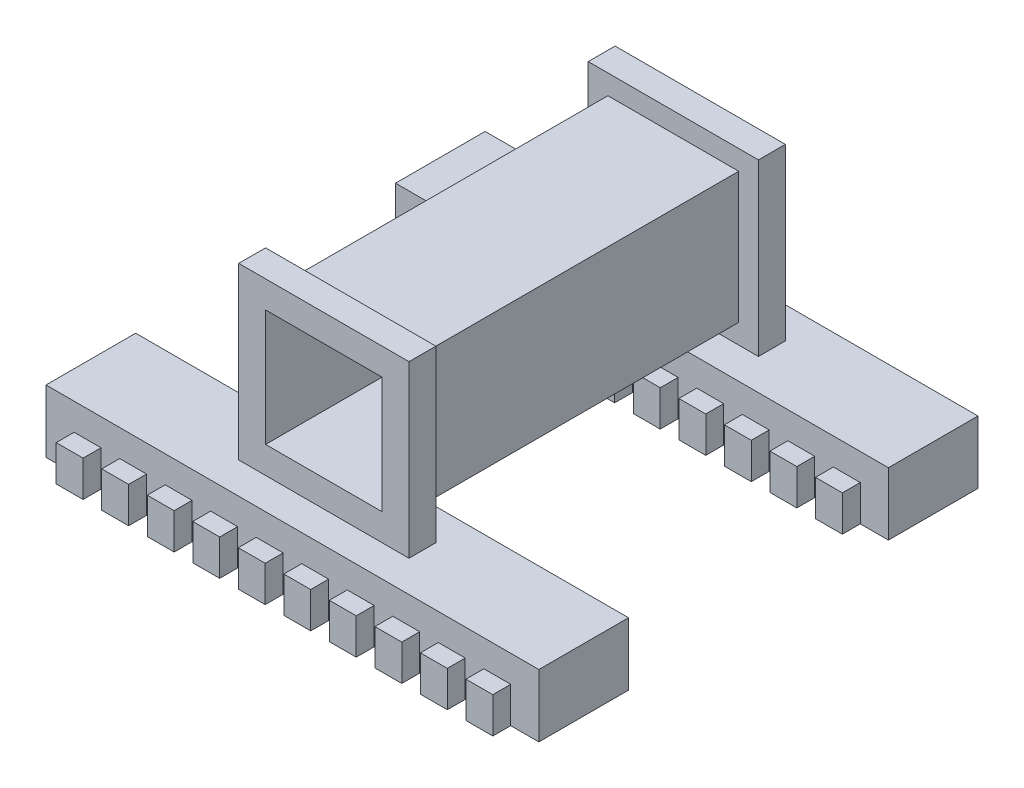
from build123d import *

# Parameters (mm, degrees)
EXTRUDE_1_DEPTH      = 21
SKETCH_1_3_W         = 13
SKETCH_1_3_H         = 13
CUT_EXTRUDE_1_DEPTH  = 21
SKETCH_1_12_W        = 19
SKETCH_1_12_H        = 19
SKETCH_1_12_W_2      = 14.6
SKETCH_1_12_H_2      = 14.6
SKETCH_1_12_W_3      = 13
SKETCH_1_12_H_3      = 13
CUT_EXTRUDE_6_DEPTH  = 18
CUT_EXTRUDE_7_DEPTH  = 14.5
SKETCH_4_W           = 3.504900739
SKETCH_4_H           = 7
SKETCH_4_W_2         = 3.5
EXTRUDE_2_DEPTH      = 27.5
SKETCH_10_W          = 1
SKETCH_10_H          = 7
EXTRUDE_4_DEPTH      = 55
SKETCH_14_W          = 1
SKETCH_14_H          = 7
EXTRUDE_6_DEPTH      = 55
SKETCH_26_W          = 1
SKETCH_26_H          = 7
EXTRUDE_7_DEPTH      = 55
CUT_EXTRUDE_27_DEPTH = 2
CUT_EXTRUDE_28_DEPTH = 2
CUT_EXTRUDE_29_DEPTH = 2
CUT_EXTRUDE_30_DEPTH = 2
SKETCH_31_W          = 49.72
SKETCH_31_H          = 3
CUT_EXTRUDE_31_DEPTH = 4


with BuildPart() as part:
    # 草图1 → 凸台-拉伸1 (new, symmetric)
    with BuildSketch(Plane.XY):
        Polygon((9.5, 9.5), (-9.5, 9.5), (-9.5, -9.5), (-27.5, -9.5), (-27.5, -16.5), (27.5, -16.5), (27.5, -9.5), (9.5, -9.5), align=None)
    extrude(amount=EXTRUDE_1_DEPTH, both=True)

    # 草图1<3> → 切除-拉伸1 (cut, symmetric)
    with BuildSketch(Plane.XY):
        Rectangle(SKETCH_1_3_W, SKETCH_1_3_H)
    extrude(amount=CUT_EXTRUDE_1_DEPTH, both=True, mode=Mode.SUBTRACT)

    # 草图1<12> → 切除-拉伸6 (cut, symmetric)
    # profile 1 of 2: a face of its own
    with BuildSketch(Plane.XY):
        Rectangle(SKETCH_1_12_W, SKETCH_1_12_H)
        Rectangle(SKETCH_1_12_W_2, SKETCH_1_12_H_2, mode=Mode.SUBTRACT)
    # profile 2 of 2: a face of its own
    with BuildSketch(Plane.XY):
        Rectangle(SKETCH_1_12_W_3, SKETCH_1_12_H_3)
    extrude(amount=CUT_EXTRUDE_6_DEPTH, both=True, mode=Mode.SUBTRACT)

    # 草图1<13> → 切除-拉伸7 (cut, symmetric)
    with BuildSketch(Plane.XY):
        Polygon((9.5, -9.5), (-9.5, -9.5), (-27.5, -9.5), (-27.5, -16.5), (27.5, -16.5), (27.5, -9.5), align=None)
    extrude(amount=CUT_EXTRUDE_7_DEPTH, both=True, mode=Mode.SUBTRACT)

    # 草图4 → 凸台-拉伸2 (add, symmetric)
    with BuildSketch(Plane(origin=(0, 0, 0), x_dir=(0, 0, -1), z_dir=(1, 0, 0))):
        with Locations((-22.752450369, -13)):
            Rectangle(SKETCH_4_W, SKETCH_4_H)
        with Locations((22.75, -13)):
            Rectangle(SKETCH_4_W_2, SKETCH_4_H)
    extrude(amount=EXTRUDE_2_DEPTH, both=True)

    # 草图10 → 凸台-拉伸4 (add)
    with BuildSketch(Plane(origin=(27.5, 0, 0), x_dir=(0, 0, -1), z_dir=(1, 0, 0))):
        with Locations((-25.004900739, -13)):
            Rectangle(SKETCH_10_W, SKETCH_10_H)
        with Locations((-14, -13)):
            Rectangle(SKETCH_10_W, SKETCH_10_H)
    extrude(amount=-EXTRUDE_4_DEPTH)

    # 草图14 → 凸台-拉伸6 (add)
    with BuildSketch(Plane(origin=(27.5, 0, 0), x_dir=(0, 0, -1), z_dir=(1, 0, 0))):
        with Locations((14, -13)):
            Rectangle(SKETCH_14_W, SKETCH_14_H)
        with Locations((25, -13)):
            Rectangle(SKETCH_14_W, SKETCH_14_H)
    extrude(amount=-EXTRUDE_6_DEPTH)

    # 草图26 → 凸台-拉伸7 (add)
    with BuildSketch(Plane(origin=(27.5, 0, 0), x_dir=(0, 0, -1), z_dir=(1, 0, 0))):
        with Locations((26, -13)):
            Rectangle(SKETCH_26_W, SKETCH_26_H)
        with Locations((13, -13)):
            Rectangle(SKETCH_26_W, SKETCH_26_H)
        with Locations((-13, -13)):
            Rectangle(SKETCH_26_W, SKETCH_26_H)
        with Locations((-26.004900739, -13)):
            Rectangle(SKETCH_26_W, SKETCH_26_H)
    extrude(amount=-EXTRUDE_7_DEPTH)

    # 草图27 → 切除-拉伸27 (cut)
    with BuildSketch(Plane(origin=(0, 0, -26.5), x_dir=(-1, 0, 0), z_dir=(0, 0, -1))):
        Polygon((-24.36, -12.5), (-22.86, -12.5), (-21.36, -12.5), (-21.36, -16.5), (-19.28, -16.5), (-19.28, -12.5), (-17.78, -12.5), (-16.28, -12.5), (-16.28, -16.5), (-14.2, -16.5), (-14.2, -12.5), (-12.7, -12.5), (-11.2, -12.5), (-11.2, -16.5), (-9.12, -16.5), (-9.12, -12.5), (-7.62, -12.5), (-6.12, -12.5), (-6.12, -16.5), (-4.04, -16.5), (-4.04, -12.5), (-2.54, -12.5), (-1.04, -12.5), (-1.04, -16.5), (1.04, -16.5), (1.04, -12.5), (2.54, -12.5), (4.04, -12.5), (4.04, -16.5), (6.12, -16.5), (6.12, -12.5), (7.62, -12.5), (9.12, -12.5), (9.12, -16.5), (11.2, -16.5), (11.2, -12.5), (12.7, -12.5), (14.2, -12.5), (14.2, -16.5), (16.28, -16.5), (16.28, -12.5), (17.78, -12.5), (19.28, -12.5), (19.28, -16.5), (21.36, -16.5), (21.36, -12.5), (22.86, -12.5), (24.36, -12.5), (24.36, -16.5), (27.5, -16.5), (27.5, -9.5), (-27.5, -9.5), (-27.5, -16.5), (-24.36, -16.5), align=None)
    extrude(amount=-CUT_EXTRUDE_27_DEPTH, mode=Mode.SUBTRACT)

    # 草图28 → 切除-拉伸28 (cut)
    with BuildSketch(Plane(origin=(0, 0, 12.5), x_dir=(-1, 0, 0), z_dir=(0, 0, -1))):
        Polygon((27.5, -9.5), (-27.5, -9.5), (-27.5, -16.5), (-24.36, -16.5), (-24.36, -12.5), (-21.36, -12.5), (-21.36, -16.5), (-19.28, -16.5), (-19.28, -12.5), (-16.28, -12.5), (-16.28, -16.5), (-14.2, -16.5), (-14.2, -12.5), (-11.2, -12.5), (-11.2, -16.5), (-9.12, -16.5), (-9.12, -12.5), (-6.12, -12.5), (-6.12, -16.5), (-4.04, -16.5), (-4.04, -12.5), (-1.04, -12.5), (-1.04, -16.5), (1.04, -16.5), (1.04, -12.5), (4.04, -12.5), (4.04, -16.5), (6.12, -16.5), (6.12, -12.5), (9.12, -12.5), (9.12, -16.5), (11.2, -16.5), (11.2, -12.5), (14.2, -12.5), (14.2, -16.5), (16.28, -16.5), (16.28, -12.5), (19.28, -12.5), (19.28, -16.5), (21.36, -16.5), (21.36, -12.5), (24.36, -12.5), (24.36, -16.5), (27.5, -16.5), align=None)
    extrude(amount=-CUT_EXTRUDE_28_DEPTH, mode=Mode.SUBTRACT)

    # 草图29 → 切除-拉伸29 (cut)
    with BuildSketch(Plane.XY.offset(-12.5)):
        Polygon((24.36, -16.5), (27.5, -16.5), (27.5, -9.5), (-27.5, -9.5), (-27.5, -16.5), (-24.36, -16.5), (-24.36, -12.5), (-21.36, -12.5), (-21.36, -16.5), (-19.28, -16.5), (-19.28, -12.5), (-16.28, -12.5), (-16.28, -16.5), (-14.2, -16.5), (-14.2, -12.5), (-11.2, -12.5), (-11.2, -16.5), (-9.12, -16.5), (-9.12, -12.5), (-6.12, -12.5), (-6.12, -16.5), (-4.04, -16.5), (-4.04, -12.5), (-1.04, -12.5), (-1.04, -16.5), (1.04, -16.5), (1.04, -12.5), (4.04, -12.5), (4.04, -16.5), (6.12, -16.5), (6.12, -12.5), (9.12, -12.5), (9.12, -16.5), (11.2, -16.5), (11.2, -12.5), (14.2, -12.5), (14.2, -16.5), (16.28, -16.5), (16.28, -12.5), (19.28, -12.5), (19.28, -16.5), (21.36, -16.5), (21.36, -12.5), (24.36, -12.5), align=None)
    extrude(amount=-CUT_EXTRUDE_29_DEPTH, mode=Mode.SUBTRACT)

    # 草图30 → 切除-拉伸30 (cut)
    with BuildSketch(Plane.XY.offset(26.504900739)):
        Polygon((24.36, -16.5), (27.5, -16.5), (27.5, -9.5), (-27.5, -9.5), (-27.5, -16.5), (-24.36, -16.5), (-24.36, -12.5), (-21.36, -12.5), (-21.36, -16.5), (-19.28, -16.5), (-19.28, -12.5), (-16.28, -12.5), (-16.28, -16.5), (-14.2, -16.5), (-14.2, -12.5), (-11.2, -12.5), (-11.2, -16.5), (-9.12, -16.5), (-9.12, -12.5), (-6.12, -12.5), (-6.12, -16.5), (-4.04, -16.5), (-4.04, -12.5), (-1.04, -12.5), (-1.04, -16.5), (1.04, -16.5), (1.04, -12.5), (4.04, -12.5), (4.04, -16.5), (6.12, -16.5), (6.12, -12.5), (9.12, -12.5), (9.12, -16.5), (11.2, -16.5), (11.2, -12.5), (14.2, -12.5), (14.2, -16.5), (16.28, -16.5), (16.28, -12.5), (19.28, -12.5), (19.28, -16.5), (21.36, -16.5), (21.36, -12.5), (24.36, -12.5), align=None)
    extrude(amount=-CUT_EXTRUDE_30_DEPTH, mode=Mode.SUBTRACT)

    # 草图31 → 切除-拉伸31 (cut)
    with BuildSketch(Plane.XZ.offset(16.5)):
        with Locations((0, 22.009047834)):
            Rectangle(SKETCH_31_W, SKETCH_31_H)
        with Locations((0, 16.995852906)):
            Rectangle(SKETCH_31_W, SKETCH_31_H)
        with Locations((0, -22.009047834)):
            Rectangle(SKETCH_31_W, SKETCH_31_H)
        with Locations((0, -16.995852906)):
            Rectangle(SKETCH_31_W, SKETCH_31_H)
    extrude(amount=-CUT_EXTRUDE_31_DEPTH, mode=Mode.SUBTRACT)


solid = part.part
